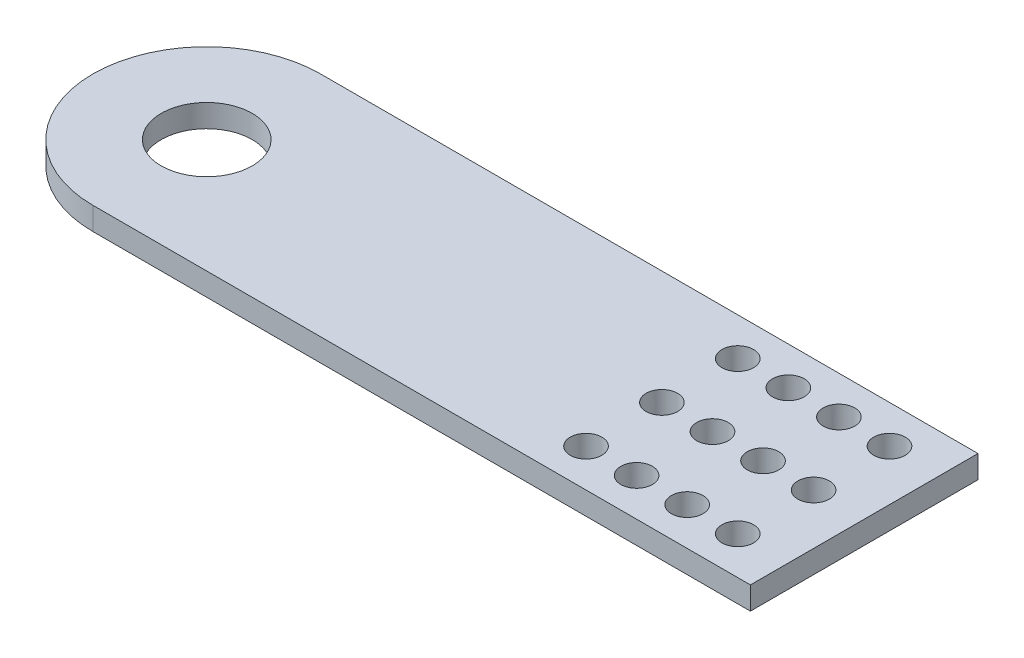
from build123d import *

# Parameters (mm, degrees)
SKETCH1_R                     = 9
BOSS_EXTRUDE1_DEPTH           = 2.25
CUT_EXTRUDE1_START            = -5.5
SKETCH2_R                     = 3.125
CUT_EXTRUDE1_DEPTH            = 6.5
LPATTERN1_COUNT               = 4
LPATTERN1_PITCH               = 10
LPATTERN2_COUNT               = 2
LPATTERN2_PITCH               = 15
LPATTERN2_START               = -5.5
LPATTERN2_COPY_1_SKETCH_R     = 3.125
LPATTERN2_COPY_1_DEPTH        = 6.5
LPATTERN2_COPY_2_SKETCH_R     = 3.125
LPATTERN2_COPY_2_DEPTH        = 6.5
LPATTERN2_COPY_3_SKETCH_R     = 3.125
LPATTERN2_COPY_3_DEPTH        = 6.5
LPATTERN2_COL_COUNT           = 2
LPATTERN2_COL_PITCH           = 15
LPATTERN2_COL_COPY_1_SKETCH_R = 3.125
LPATTERN2_COL_COPY_1_DEPTH    = 6.5
LPATTERN2_COL_COPY_2_SKETCH_R = 3.125
LPATTERN2_COL_COPY_2_DEPTH    = 6.5
LPATTERN2_COL_COPY_3_SKETCH_R = 3.125
LPATTERN2_COL_COPY_3_DEPTH    = 6.5
CUT_EXTRUDE2_DEPTH            = 1
CUT_EXTRUDE2_DEPTH_BACK       = 5.5


with BuildPart() as part:
    # Sketch1 → Boss-Extrude1 (new body, symmetric)
    with BuildSketch(Plane(origin=(0, 0, 0), x_dir=(1, 0, 0), z_dir=(0, 1, 0))):
        Polygon((130, -22.5), (0, -22.5), (-30, -22.5), (-30, 22.5), (0, 22.5), (130, 22.5), align=None)
        Circle(SKETCH1_R, mode=Mode.SUBTRACT)
    extrude(amount=BOSS_EXTRUDE1_DEPTH, both=True)

    # Sketch2 → Cut-Extrude1 (cut)
    with BuildSketch(Plane(origin=(0, 2.25, 0), x_dir=(1, 0, 0), z_dir=(0, 1, 0)).offset(CUT_EXTRUDE1_START)):
        with Locations((120, 0)):
            Circle(SKETCH2_R)
    cut_extrude1 = extrude(amount=CUT_EXTRUDE1_DEPTH, mode=Mode.SUBTRACT)

    # LPattern1: Cut-Extrude1 ×4
    with Locations(*[(-i * LPATTERN1_PITCH, 0, 0) for i in range(1, LPATTERN1_COUNT)]):
        add(cut_extrude1, mode=Mode.SUBTRACT)

    # LPattern2: Cut-Extrude1 ×2
    with Locations(*[(0, 0, i * LPATTERN2_PITCH) for i in range(1, LPATTERN2_COUNT)]):
        add(cut_extrude1, mode=Mode.SUBTRACT)

    # LPattern2 copy 1 sketch → LPattern2 copy 1 (cut)
    with BuildSketch(Plane(origin=(-10, 2.25, 15), x_dir=(1, 0, 0), z_dir=(0, 1, 0)).offset(LPATTERN2_START)):
        with Locations((120, 0)):
            Circle(LPATTERN2_COPY_1_SKETCH_R)
    extrude(amount=LPATTERN2_COPY_1_DEPTH, mode=Mode.SUBTRACT)

    # LPattern2 copy 2 sketch → LPattern2 copy 2 (cut)
    with BuildSketch(Plane(origin=(-20, 2.25, 15), x_dir=(1, 0, 0), z_dir=(0, 1, 0)).offset(LPATTERN2_START)):
        with Locations((120, 0)):
            Circle(LPATTERN2_COPY_2_SKETCH_R)
    extrude(amount=LPATTERN2_COPY_2_DEPTH, mode=Mode.SUBTRACT)

    # LPattern2 copy 3 sketch → LPattern2 copy 3 (cut)
    with BuildSketch(Plane(origin=(-30, 2.25, 15), x_dir=(1, 0, 0), z_dir=(0, 1, 0)).offset(LPATTERN2_START)):
        with Locations((120, 0)):
            Circle(LPATTERN2_COPY_3_SKETCH_R)
    extrude(amount=LPATTERN2_COPY_3_DEPTH, mode=Mode.SUBTRACT)

    # LPattern2 col: Cut-Extrude1 ×2
    with Locations(*[(0, 0, -i * LPATTERN2_COL_PITCH) for i in range(1, LPATTERN2_COL_COUNT)]):
        add(cut_extrude1, mode=Mode.SUBTRACT)

    # LPattern2 col copy 1 sketch → LPattern2 col copy 1 (cut)
    with BuildSketch(Plane(origin=(-10, 2.25, -15), x_dir=(1, 0, 0), z_dir=(0, 1, 0)).offset(LPATTERN2_START)):
        with Locations((120, 0)):
            Circle(LPATTERN2_COL_COPY_1_SKETCH_R)
    extrude(amount=LPATTERN2_COL_COPY_1_DEPTH, mode=Mode.SUBTRACT)

    # LPattern2 col copy 2 sketch → LPattern2 col copy 2 (cut)
    with BuildSketch(Plane(origin=(-20, 2.25, -15), x_dir=(1, 0, 0), z_dir=(0, 1, 0)).offset(LPATTERN2_START)):
        with Locations((120, 0)):
            Circle(LPATTERN2_COL_COPY_2_SKETCH_R)
    extrude(amount=LPATTERN2_COL_COPY_2_DEPTH, mode=Mode.SUBTRACT)

    # LPattern2 col copy 3 sketch → LPattern2 col copy 3 (cut)
    with BuildSketch(Plane(origin=(-30, 2.25, -15), x_dir=(1, 0, 0), z_dir=(0, 1, 0)).offset(LPATTERN2_START)):
        with Locations((120, 0)):
            Circle(LPATTERN2_COL_COPY_3_SKETCH_R)
    extrude(amount=LPATTERN2_COL_COPY_3_DEPTH, mode=Mode.SUBTRACT)

    # Sketch3 → Cut-Extrude2 (cut, two sides)
    with BuildSketch(Plane(origin=(0, 2.25, 0), x_dir=(1, 0, 0), z_dir=(0, 1, 0))) as cut_extrude2_sk:
        with BuildLine():
            ThreePointArc((-4.9e-08, -22.5), (-22.5, 2.1e-08), (-7e-09, 22.5))
            Line((-7e-09, 22.5), (-30, 22.5))
            Line((-30, 22.5), (-30, -22.5))
            Line((-30, -22.5), (-4.9e-08, -22.5))
        make_face()
    extrude(amount=CUT_EXTRUDE2_DEPTH, mode=Mode.SUBTRACT)
    extrude(cut_extrude2_sk.sketch, amount=-CUT_EXTRUDE2_DEPTH_BACK, mode=Mode.SUBTRACT)


solid = part.part
